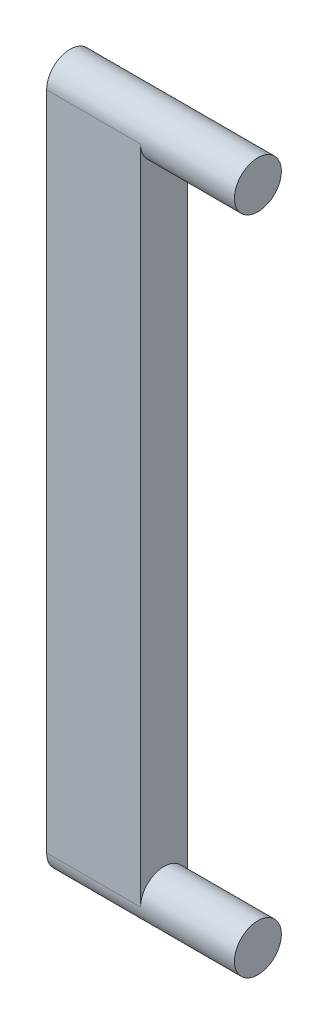
from build123d import *
from build123d.topology import SkipClean

# Parameters (mm, degrees)
ESQUISSE1_R        = 2.5
BOSS_EXTRU_1_DEPTH = 10
BOSS_EXTRU_2_DEPTH = 10
ESQUISSE4_R        = 2.5
BOSS_EXTRU_4_DEPTH = 10


with BuildPart() as part:
    # Esquisse1 → Boss.-Extru.1 (new body)
    with BuildSketch(Plane(origin=(0, 0, 0), x_dir=(0, 0, -1), z_dir=(1, 0, 0))):
        Circle(ESQUISSE1_R)
    extrude(amount=-BOSS_EXTRU_1_DEPTH)

    # Esquisse2 → Boss.-Extru.2 (add)
    with SkipClean():  # keep this step's faces unmerged: merging them makes the solid invalid here
        with BuildSketch(Plane.ZY.offset(10)):
            with BuildLine():
                Line((-2.5, 0), (-2.5, -70.37))
                ThreePointArc((-2.5, -70.37), (0, -72.87), (2.5, -70.37))
                Line((2.5, -70.37), (2.5, 0))
                ThreePointArc((2.5, 0), (0, 2.5), (-2.5, 0))
            make_face()
        extrude(amount=BOSS_EXTRU_2_DEPTH)

    # Esquisse4 → Boss.-Extru.4 (add)
    with SkipClean():  # keep this step's faces unmerged: merging them makes the solid invalid here
        with BuildSketch(Plane(origin=(-10, 0, 0), x_dir=(0, 0, -1), z_dir=(1, 0, 0))):
            with Locations((0, -70.37)):
                Circle(ESQUISSE4_R)
        extrude(amount=BOSS_EXTRU_4_DEPTH)


solid = part.part
